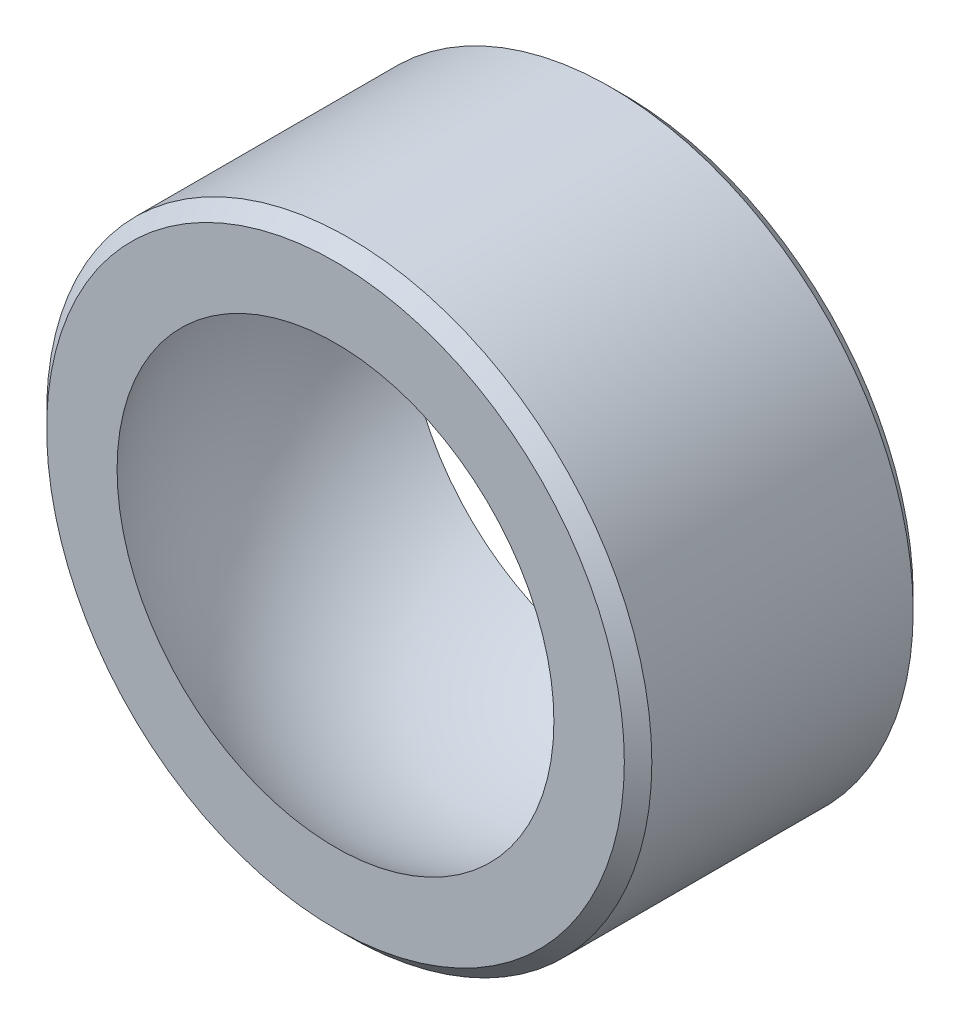
from build123d import *

# Parameters (mm, degrees)
SKETCH2_R           = 11
BOSS_EXTRUDE1_DEPTH = 5.25
CHAMFER1_SIZE       = 0.5


with BuildPart() as part:
    # Sketch2 → Boss-Extrude1 (new body, symmetric)
    with BuildSketch(Plane.XY):
        Circle(SKETCH2_R)
    extrude(amount=BOSS_EXTRUDE1_DEPTH, both=True)

    # Sketch4 → Cut-Revolve1 (revolve, cut)
    with BuildSketch(Plane(origin=(0, 0, 0), x_dir=(0, 0, -1), z_dir=(1, 0, 0))):
        with BuildLine():
            Line((7, -6.45), (7, 0))
            Line((7, 0), (-7, 0))
            Line((-7, 0), (-7, -6.45))
            ThreePointArc((-7, -6.45), (0, -9.518534551), (7, -6.45))
        make_face()
    revolve(axis=Axis((0, 0, -7), (0, 0, 1)), mode=Mode.SUBTRACT)

    # Chamfer1
    chamfer1_edges = [part.edges().sort_by_distance(p)[0] for p in [
        (-11, 0, -5.25),
        (-11, 0, 5.25),
    ]]
    chamfer(chamfer1_edges, length=CHAMFER1_SIZE)


solid = part.part
